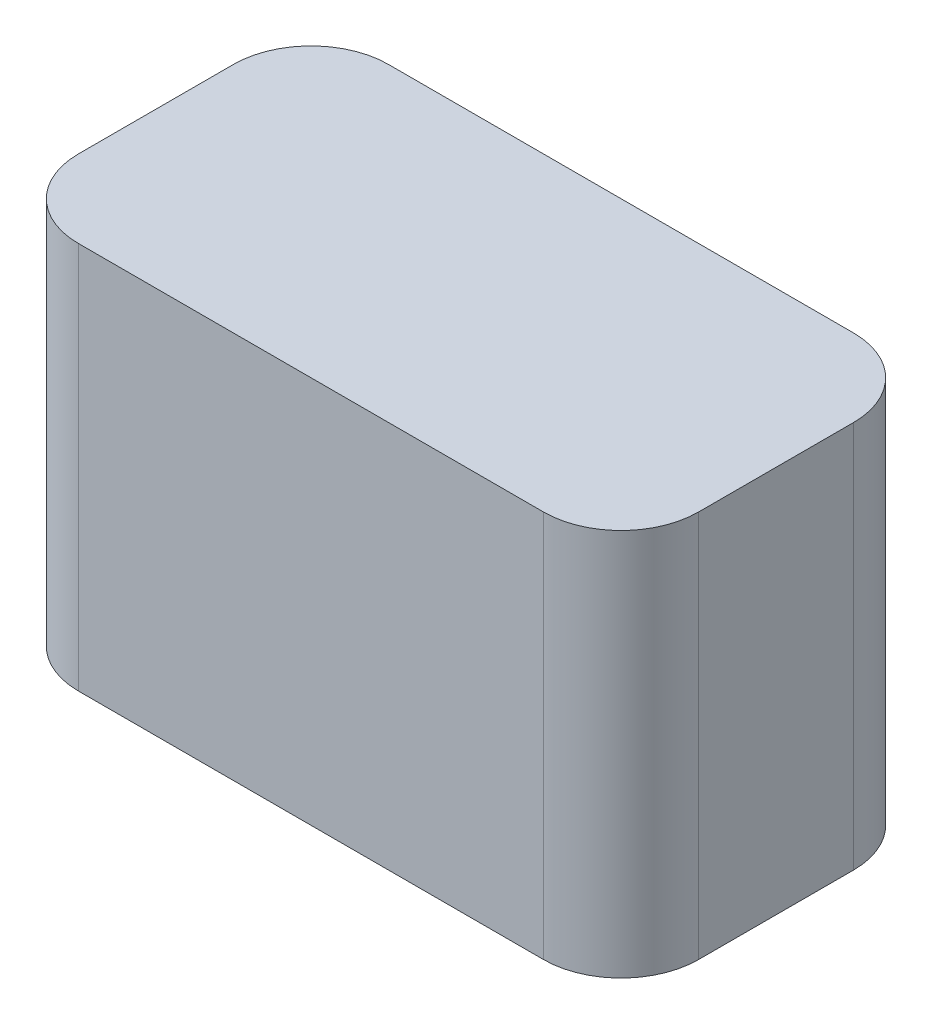
from build123d import *

# Parameters (mm, degrees)
BOSS_EXTRUDE1_DEPTH = 5


with BuildPart() as part:
    # Sketch1 → Boss-Extrude1 (new body)
    with BuildSketch(Plane(origin=(0, 0, 0), x_dir=(1, 0, 0), z_dir=(0, 1, 0))):
        with BuildLine():
            Line((-3, 2), (3, 2))
            ThreePointArc((3, 2), (3.707106781, 1.707106781), (4, 1))
            Line((4, 1), (4, -1))
            ThreePointArc((4, -1), (3.707106781, -1.707106781), (3, -2))
            Line((3, -2), (-3, -2))
            ThreePointArc((-3, -2), (-3.707106781, -1.707106781), (-4, -1))
            Line((-4, -1), (-4, 1))
            ThreePointArc((-4, 1), (-3.707106781, 1.707106781), (-3, 2))
        make_face()
    extrude(amount=BOSS_EXTRUDE1_DEPTH)


solid = part.part
